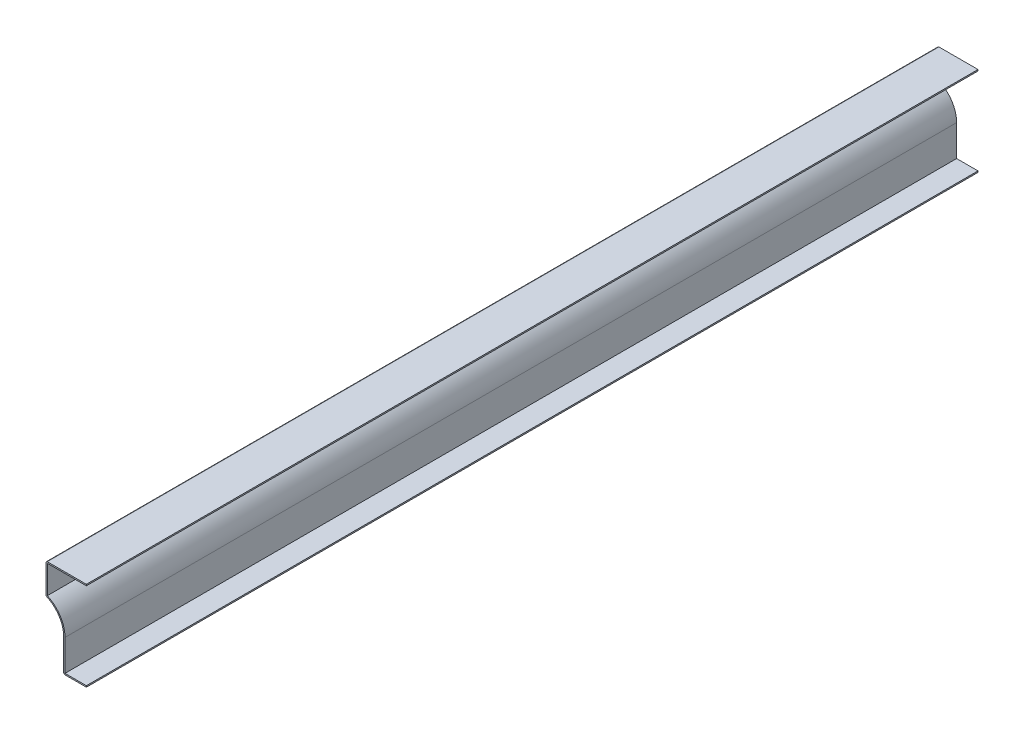
from build123d import *

# Parameters (mm, degrees)
EXTRUDE_THIN1_DEPTH = 841.375
FILLET1_R           = 1.27


with BuildPart() as part:
    # Sketch1 → Extrude-Thin1 (new body)
    with BuildSketch(Plane.XY):
        with BuildLine():
            Line((0, 0), (-21.43125, 0))
            Line((-21.43125, 0), (-21.43125, 30.62560856))
            ThreePointArc((-21.43125, 30.62560856), (-25.982145735, 45.62307319), (-38.1, 55.5625))
            Line((-38.1, 55.5625), (-38.1, 84.1375))
            Line((-38.1, 84.1375), (0, 84.1375))
            Line((0, 84.1375), (0, 82.8675))
            Line((0, 82.8675), (-36.83, 82.8675))
            Line((-36.83, 82.8675), (-36.83, 56.397437748))
            ThreePointArc((-36.83, 56.397437748), (-24.691598787, 45.971898065), (-20.16125, 30.62560856))
            Line((-20.16125, 30.62560856), (-20.16125, 1.27))
            Line((-20.16125, 1.27), (0, 1.27))
            Line((0, 1.27), (0, 0))
        make_face()
    extrude(amount=-EXTRUDE_THIN1_DEPTH)

    # Fillet1
    fillet1_edges = [part.edges().sort_by_distance(p)[0] for p in [
        (-21.43125, 0, -420.6875),
        (-38.1, 55.5625, -420.6875),
        (-38.1, 84.1375, -420.6875),
    ]]
    fillet(fillet1_edges, radius=FILLET1_R)


solid = part.part
